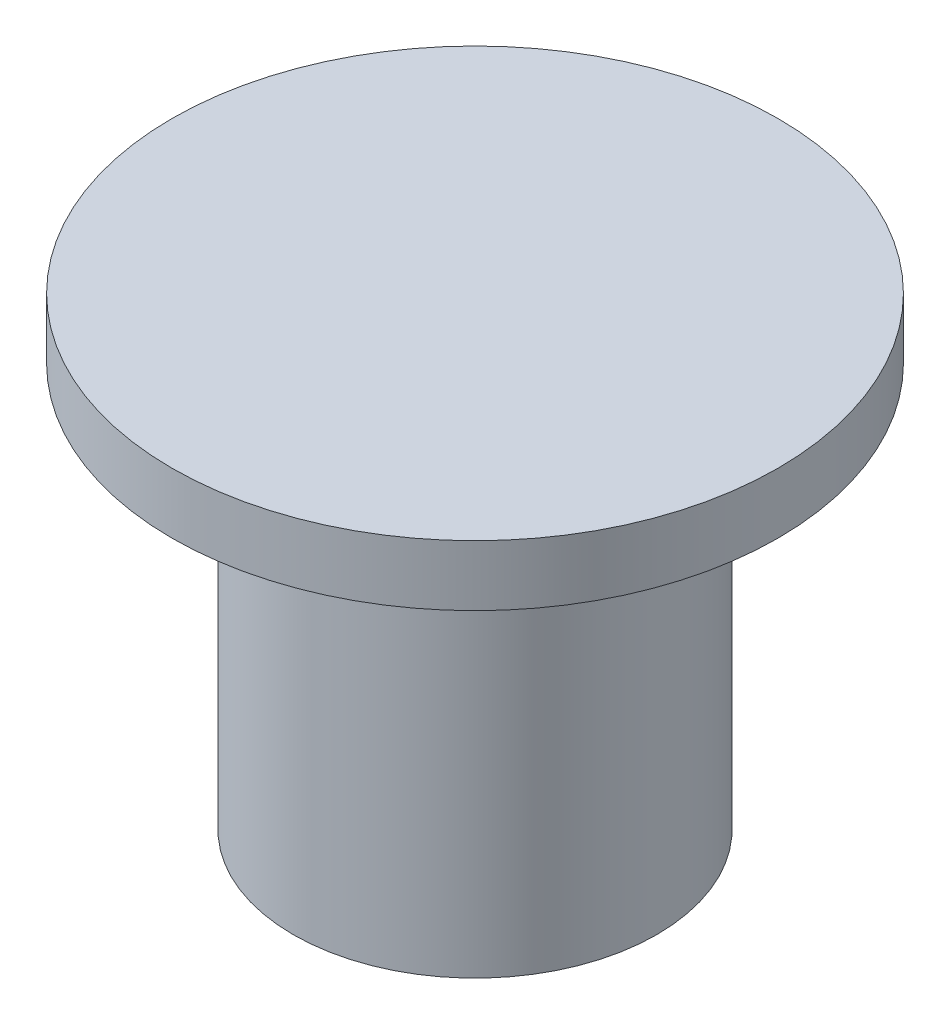
from build123d import *


with BuildPart() as part:
    # Croquis1 → Revolución1 (revolve)
    with BuildSketch(Plane.XY):
        Polygon((-79.537175428, 27.674787776), (-87.037175428, 27.674787776), (-87.037175428, 26.174787776), (-84.037175428, 26.174787776), (-84.037175428, 16.174787776), (-83.037175428, 16.174787776), (-83.037175428, 26.174787776), (-79.537175428, 26.174787776), align=None)
    revolve(axis=Axis((-79.537175428, 26.174787776, 0), (0, 1, 0)))


solid = part.part
